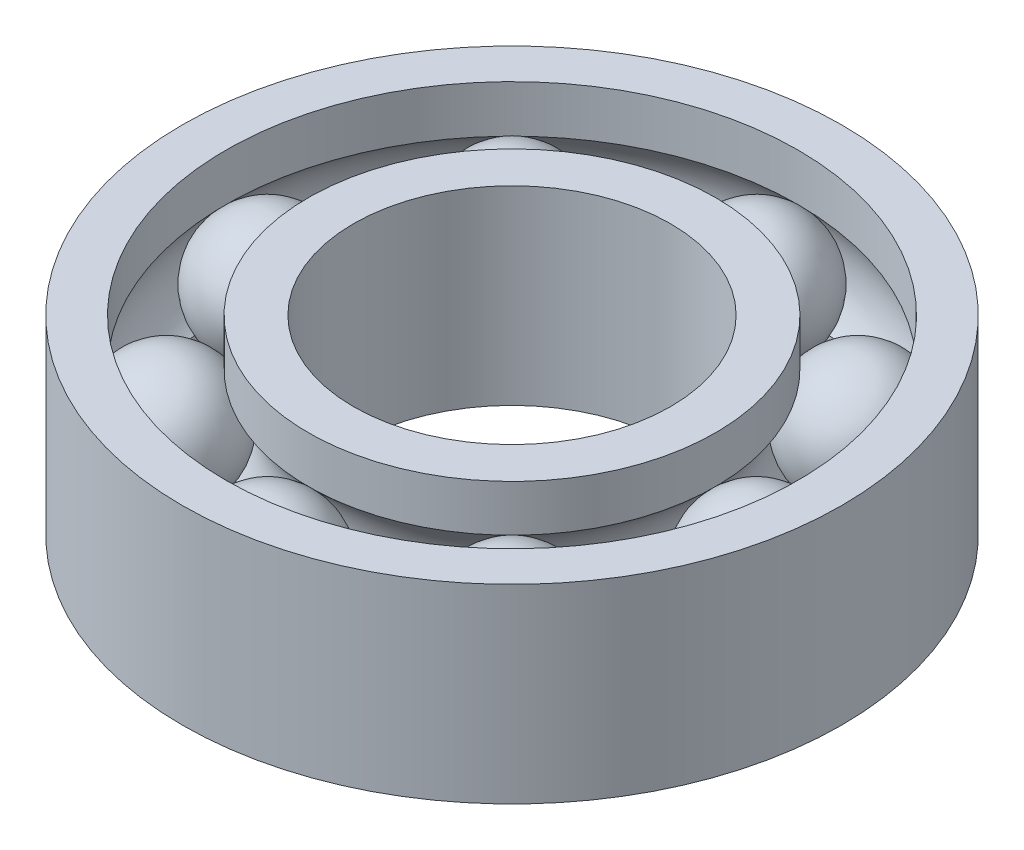
from build123d import *

# Parameters (mm, degrees)
CIRPATTERN1_COUNT = 8


with BuildPart() as part:
    # Sketch1 → Revolve2 (revolve)
    with BuildSketch(Plane.XY):
        with BuildLine():
            ThreePointArc((-22.558875638, 3.774292992), (-24.279437819, 0), (-22.558875638, -3.774292992))
            ThreePointArc((-22.558875638, -3.774292992), (-21.029942752, -4.683559809), (-19.279437819, -5))
            Line((-19.279437819, -5), (-19.279437819, 5))
            ThreePointArc((-19.279437819, 5), (-21.029942752, 4.683559809), (-22.558875638, 3.774292992))
        make_face()
    revolve(axis=Axis((-19.279437819, -6.112760854, 0), (0, 1, 0)))


with BuildPart() as body_2:
    # Sketch1_5 → Revolve3 (revolve)
    with BuildSketch(Plane.XY):
        with BuildLine():
            Line((-22.558875638, -7.5), (-22.558875638, -3.774292992))
            ThreePointArc((-22.558875638, -3.774292992), (-24.279437819, 0), (-22.558875638, 3.774292992))
            Line((-22.558875638, 3.774292992), (-22.558875638, 7.5))
            Line((-22.558875638, 7.5), (-26, 7.5))
            Line((-26, 7.5), (-26, -7.5))
            Line((-26, -7.5), (-22.558875638, -7.5))
        make_face()
        with BuildLine():
            Line((-12.5, 7.5), (-16.058875638, 7.5))
            Line((-16.058875638, 7.5), (-16.058875638, 3.824654133))
            ThreePointArc((-16.058875638, 3.824654133), (-14.279437819, 0), (-16.058875638, -3.824654133))
            Line((-16.058875638, -3.824654133), (-16.058875638, -7.5))
            Line((-16.058875638, -7.5), (-12.5, -7.5))
            Line((-12.5, -7.5), (-12.5, 7.5))
        make_face()
    revolve(axis=Axis((0, -15.906758569, 0), (0, 1, 0)))


with BuildPart() as cirpattern1_1:
    # CirPattern1: pattern copy
    add(part.part.rotate(Axis((0, 0, 0), (0, 1, 0)), 1 * 360 / CIRPATTERN1_COUNT))


with BuildPart() as cirpattern1_2:
    # CirPattern1: pattern copy
    add(part.part.rotate(Axis((0, 0, 0), (0, 1, 0)), 2 * 360 / CIRPATTERN1_COUNT))


with BuildPart() as cirpattern1_3:
    # CirPattern1: pattern copy
    add(part.part.rotate(Axis((0, 0, 0), (0, 1, 0)), 3 * 360 / CIRPATTERN1_COUNT))


with BuildPart() as cirpattern1_4:
    # CirPattern1: pattern copy
    add(part.part.rotate(Axis((0, 0, 0), (0, 1, 0)), 4 * 360 / CIRPATTERN1_COUNT))


with BuildPart() as cirpattern1_5:
    # CirPattern1: pattern copy
    add(part.part.rotate(Axis((0, 0, 0), (0, 1, 0)), 5 * 360 / CIRPATTERN1_COUNT))


with BuildPart() as cirpattern1_6:
    # CirPattern1: pattern copy
    add(part.part.rotate(Axis((0, 0, 0), (0, 1, 0)), 6 * 360 / CIRPATTERN1_COUNT))


with BuildPart() as cirpattern1_7:
    # CirPattern1: pattern copy
    add(part.part.rotate(Axis((0, 0, 0), (0, 1, 0)), 7 * 360 / CIRPATTERN1_COUNT))


solid = Compound([part.part, body_2.part, cirpattern1_1.part, cirpattern1_2.part, cirpattern1_3.part, cirpattern1_4.part, cirpattern1_5.part, cirpattern1_6.part, cirpattern1_7.part])
